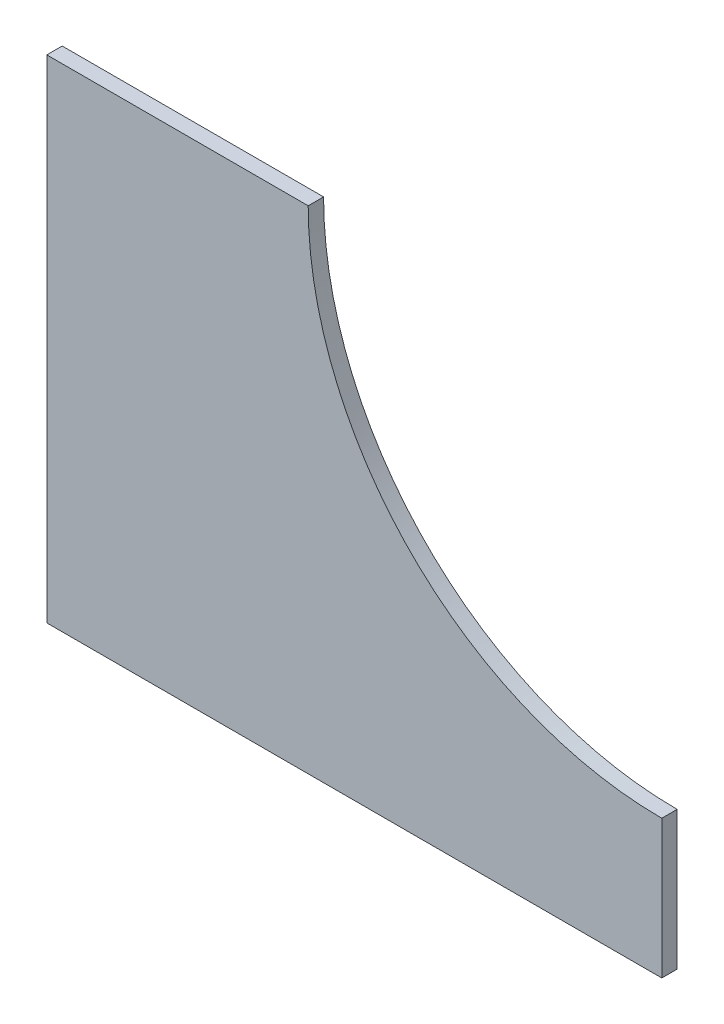
from build123d import *

# Parameters (mm, degrees)
BOSS_EXTRUDE1_DEPTH = 3.175


with BuildPart() as part:
    # Sketch1 → Boss-Extrude1 (new body)
    with BuildSketch(Plane.XY):
        with BuildLine():
            Line((98.429478474, -196.654958099), (98.429478474, -225.229958099))
            Line((98.429478474, -225.229958099), (-28.570521526, -225.229958099))
            Line((-28.570521526, -225.229958099), (-28.570521526, -123.629958099))
            Line((-28.570521526, -123.629958099), (25.404478474, -123.629958099))
            ThreePointArc((25.404478474, -123.629958099), (46.793005778, -175.266430795), (98.429478474, -196.654958099))
        make_face()
    extrude(amount=BOSS_EXTRUDE1_DEPTH)


solid = part.part
